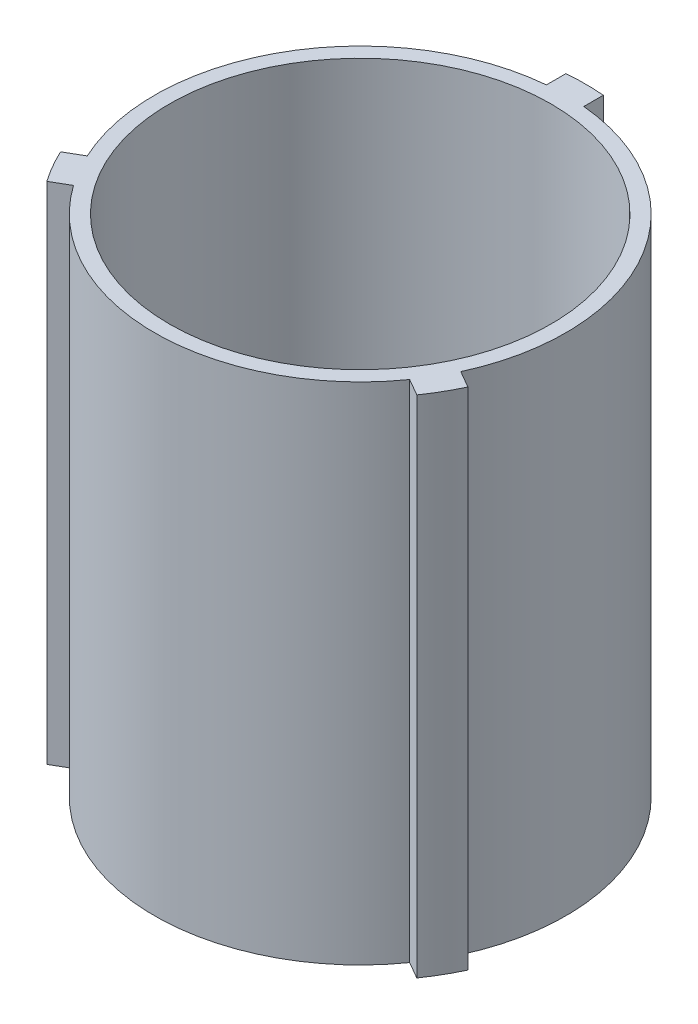
from build123d import *

# Parameters (mm, degrees)
SKETCH1_R           = 32.385
BOSS_EXTRUDE1_DEPTH = 85.725


with BuildPart() as part:
    # Sketch1 → Boss-Extrude1 (new body)
    with BuildSketch(Plane(origin=(0, 0, 0), x_dir=(1, 0, 0), z_dir=(0, 1, 0))):
        with BuildLine():
            Line((-3.175, 34.780382402), (-3.175, 38.094919661))
            ThreePointArc((-3.175, 38.094919661), (0, 38.227), (3.175, 38.094919661))
            Line((3.175, 38.094919661), (3.175, 34.780382402))
            ThreePointArc((3.175, 34.780382402), (30.245937227, 17.4625), (31.708194713, -14.640560544))
            Line((31.708194713, -14.640560544), (34.578668182, -16.297829174))
            ThreePointArc((34.578668182, -16.297829174), (33.10555311, -19.1135), (31.403668182, -21.797090488))
            Line((31.403668182, -21.797090488), (28.533194713, -20.139821858))
            ThreePointArc((28.533194713, -20.139821858), (0, -34.925), (-28.533194713, -20.139821858))
            Line((-28.533194713, -20.139821858), (-31.403668182, -21.797090488))
            ThreePointArc((-31.403668182, -21.797090488), (-33.10555311, -19.1135), (-34.578668182, -16.297829174))
            Line((-34.578668182, -16.297829174), (-31.708194713, -14.640560544))
            ThreePointArc((-31.708194713, -14.640560544), (-30.245937227, 17.4625), (-3.175, 34.780382402))
        make_face()
        Circle(SKETCH1_R, mode=Mode.SUBTRACT)
    extrude(amount=BOSS_EXTRUDE1_DEPTH)


solid = part.part
